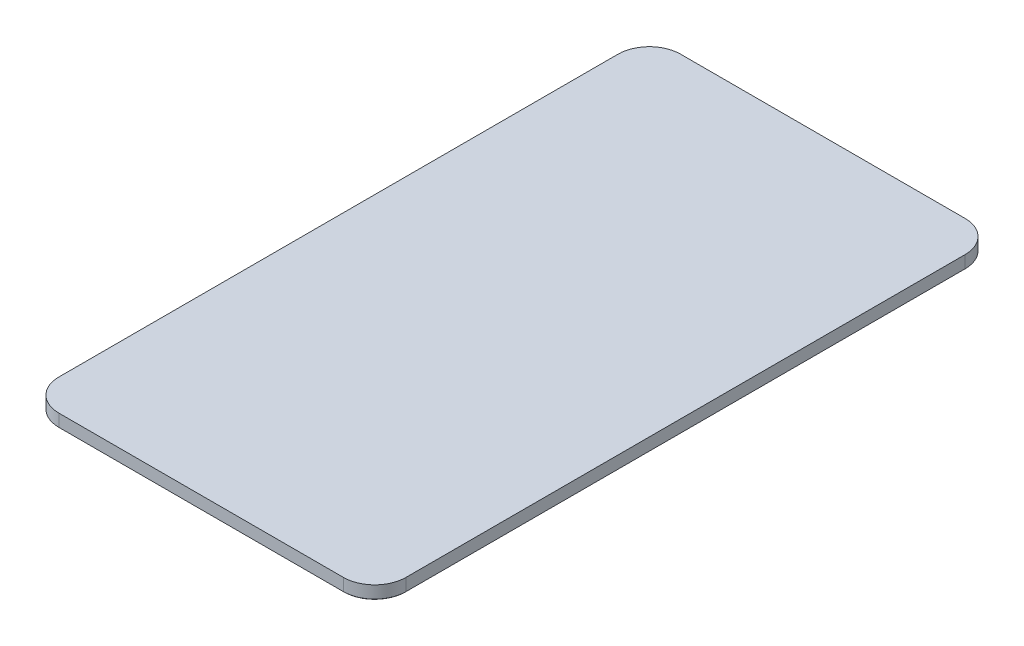
from build123d import *

# Parameters (mm, degrees)
SKETCH1_W           = 160.528
SKETCH1_H           = 287.528
BOSS_EXTRUDE1_DEPTH = 5.969
FILLET2_R           = 14.478
CHAMFER1_SIZE       = 0.254


with BuildPart() as part:
    # Sketch1 → Boss-Extrude1 (new body)
    with BuildSketch(Plane(origin=(0, 0, 0), x_dir=(1, 0, 0), z_dir=(0, 1, 0))):
        with Locations((80.264, 143.764)):
            Rectangle(SKETCH1_W, SKETCH1_H)
    extrude(amount=BOSS_EXTRUDE1_DEPTH)

    # Fillet2
    fillet2_edges = [part.edges().sort_by_distance(p)[0] for p in [
        (0, 2.9845, -287.528),
        (160.528, 2.9845, -287.528),
        (160.528, 2.9845, 0),
        (0, 2.9845, 0),
    ]]
    fillet(fillet2_edges, radius=FILLET2_R)

    # Chamfer1
    chamfer1_edges = [part.edges().sort_by_distance(p)[0] for p in [
        (80.264, 0, -287.528),
        (0, 0, -143.764),
        (160.528, 0, -143.764),
        (80.264, 0, 0),
        (4.240508022, 0, -283.287491978),
        (4.240508022, 0, -4.240508022),
        (156.287491978, 0, -4.240508022),
        (156.287491978, 0, -283.287491978),
    ]]
    chamfer(chamfer1_edges, length=CHAMFER1_SIZE)


solid = part.part
